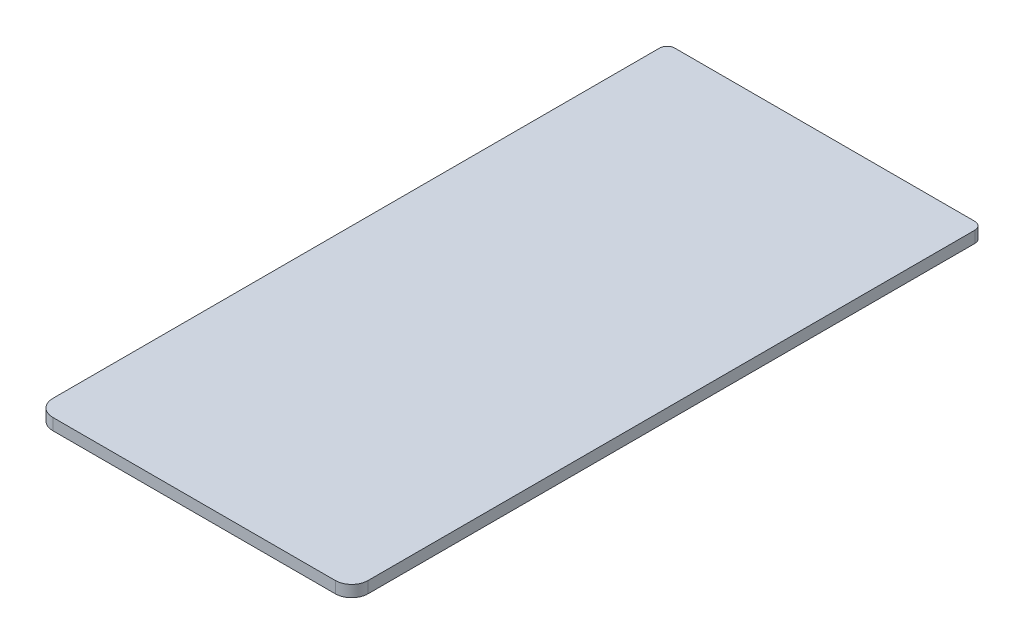
from build123d import *

# Parameters (mm, degrees)
BOSS_EXTRU_1_DEPTH = 1


with BuildPart() as part:
    # Esquisse1 → Boss.-Extru.1 (new body)
    with BuildSketch(Plane(origin=(0, 0, 0), x_dir=(1, 0, 0), z_dir=(0, 1, 0))):
        with BuildLine():
            Line((-12.99, 27.311993172), (12.99, 27.311993172))
            ThreePointArc((12.99, 27.311993172), (13.458458243, 27.117951415), (13.6525, 26.649493172))
            Line((13.6525, 26.649493172), (13.6525, -25.891993172))
            ThreePointArc((13.6525, -25.891993172), (13.236591629, -26.896084801), (12.2325, -27.311993172))
            Line((12.2325, -27.311993172), (-12.2325, -27.311993172))
            ThreePointArc((-12.2325, -27.311993172), (-13.236591629, -26.896084801), (-13.6525, -25.891993172))
            Line((-13.6525, -25.891993172), (-13.6525, 26.649493172))
            ThreePointArc((-13.6525, 26.649493172), (-13.458458243, 27.117951415), (-12.99, 27.311993172))
        make_face()
    extrude(amount=BOSS_EXTRU_1_DEPTH)


solid = part.part
